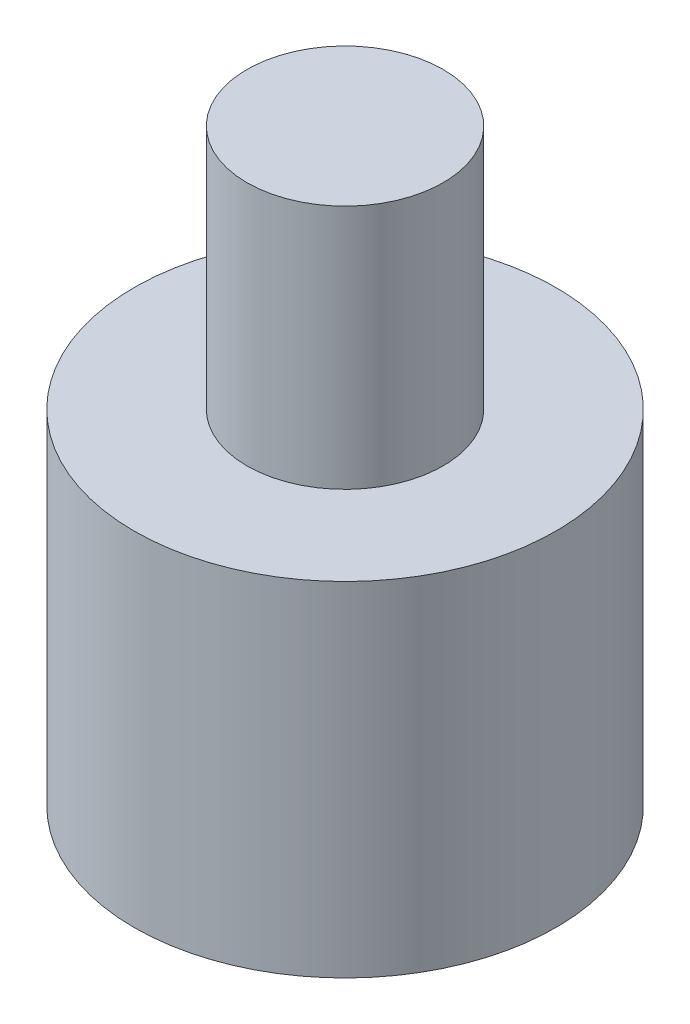
from build123d import *

# Parameters (mm, degrees)
SKETCH1_R                 = 2.15
BOSS_EXTRUDE1_DEPTH       = 6
SKETCH2_R                 = 2.15
SKETCH2_R_2               = 1
CUT_EXTRUDE1_DEPTH        = 2.5
M2X0_4_TAPPED_HOLE1_D     = 1.6
M2X0_4_TAPPED_HOLE1_DEPTH = 3.5
M2X0_4_TAPPED_HOLE1_TIP   = 0.480688495


with BuildPart() as part:
    # Sketch1 → Boss-Extrude1 (new body)
    with BuildSketch(Plane(origin=(0, 0, 0), x_dir=(1, 0, 0), z_dir=(0, 1, 0))):
        Circle(SKETCH1_R)
    extrude(amount=BOSS_EXTRUDE1_DEPTH)

    # Sketch2 → Cut-Extrude1 (cut)
    with BuildSketch(Plane(origin=(0, 6, 0), x_dir=(1, 0, 0), z_dir=(0, 1, 0))):
        Circle(SKETCH2_R)
        Circle(SKETCH2_R_2, mode=Mode.SUBTRACT)
    extrude(amount=-CUT_EXTRUDE1_DEPTH, mode=Mode.SUBTRACT)

    # M2x0.4 Tapped Hole1
    with Locations(Plane.XZ):
        with Locations((0, 0)):
            Hole(M2X0_4_TAPPED_HOLE1_D / 2, depth=M2X0_4_TAPPED_HOLE1_DEPTH)
            with Locations((0, 0, -(M2X0_4_TAPPED_HOLE1_DEPTH + M2X0_4_TAPPED_HOLE1_TIP / 2))):  # 118° drill point
                Cone(0, M2X0_4_TAPPED_HOLE1_D / 2, M2X0_4_TAPPED_HOLE1_TIP, mode=Mode.SUBTRACT)


solid = part.part
